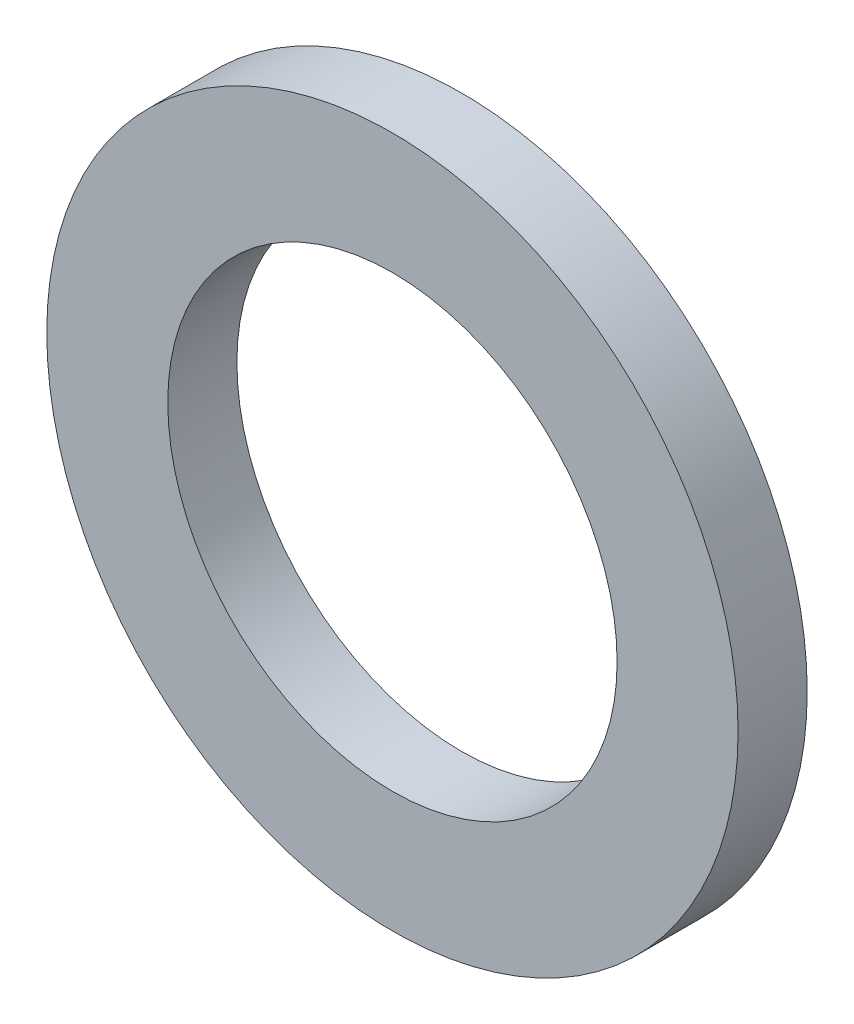
from build123d import *

# Parameters (mm, degrees)
CROQUIS1_R              = 5
CROQUIS1_R_2            = 3.25
SALIENTE_EXTRUIR1_DEPTH = 1


with BuildPart() as part:
    # Croquis1 → Saliente-Extruir1 (new body)
    with BuildSketch(Plane.XY):
        Circle(CROQUIS1_R)
        Circle(CROQUIS1_R_2, mode=Mode.SUBTRACT)
    extrude(amount=SALIENTE_EXTRUIR1_DEPTH)


solid = part.part
